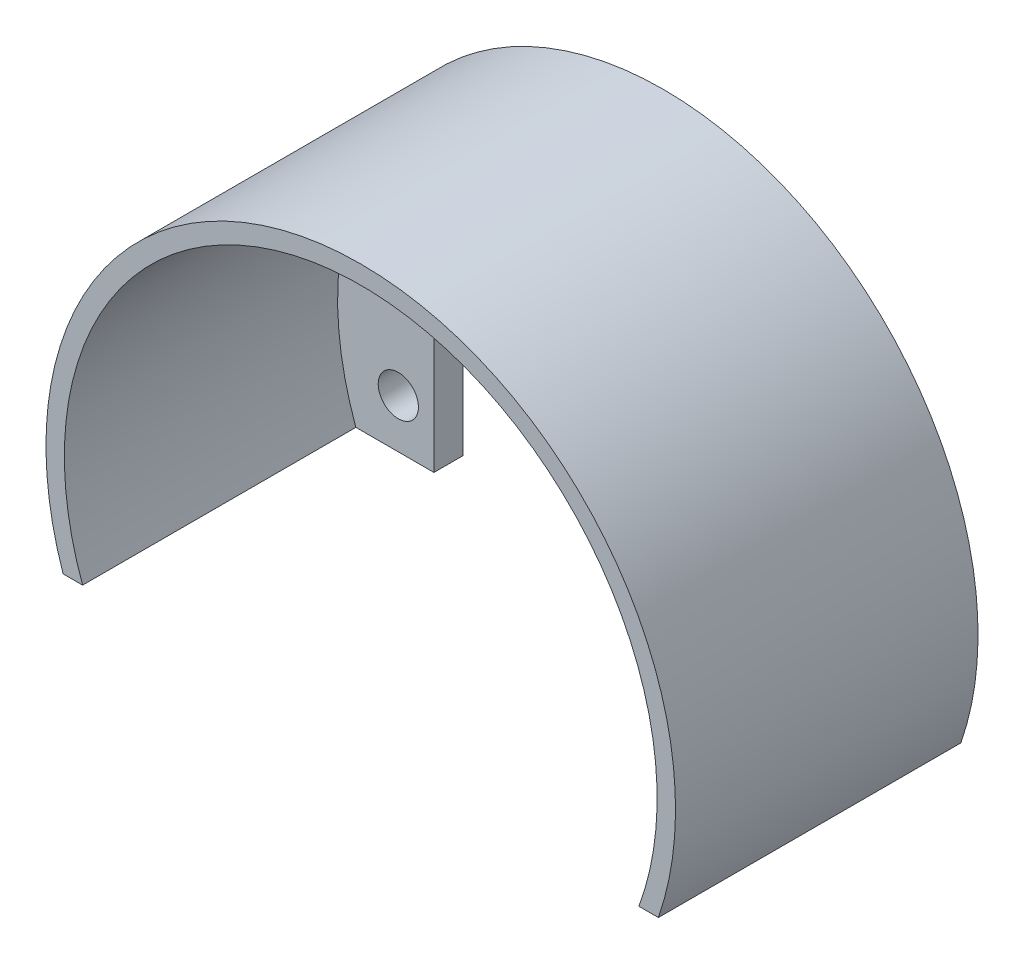
from build123d import *

# Parameters (mm, degrees)
CROQUIS1_R              = 2.060946668
SALIENTE_EXTRUIR1_DEPTH = 3
SALIENTE_EXTRUIR2_DEPTH = 28


with BuildPart() as part:
    # Croquis1 → Saliente-Extruir1 (new body)
    with BuildSketch(Plane.XY):
        with BuildLine():
            Line((-17.644764035, 22.151573595), (23.355235965, 22.151573595))
            Line((23.355235965, 22.151573595), (23.355235965, 1.151573595))
            Line((23.355235965, 1.151573595), (33.355235965, 1.151573595))
            ThreePointArc((33.355235965, 1.151573595), (2.855235965, 43.908355827), (-27.644764035, 1.151573595))
            Line((-27.644764035, 1.151573595), (-17.644764035, 1.151573595))
            Line((-17.644764035, 1.151573595), (-17.644764035, 22.151573595))
        make_face()
        with Locations((27.005235965, 6.151573595)):
            Circle(CROQUIS1_R, mode=Mode.SUBTRACT)
        with Locations((-21.294764035, 6.151573595)):
            Circle(CROQUIS1_R, mode=Mode.SUBTRACT)
        with Locations((-21.294764035, 16.151573595)):
            Circle(CROQUIS1_R, mode=Mode.SUBTRACT)
        with Locations((27.005235965, 16.151573595)):
            Circle(CROQUIS1_R, mode=Mode.SUBTRACT)
    extrude(amount=SALIENTE_EXTRUIR1_DEPTH)

    # Croquis2 → Saliente-Extruir2 (add)
    with BuildSketch(Plane.XY.offset(3)):
        with BuildLine():
            Line((-27.644764035, 1.151573595), (-25.644764035, 1.151573595))
            ThreePointArc((-25.644764035, 1.151573595), (2.855235965, 42.024258692), (31.355235965, 1.151573595))
            Line((31.355235965, 1.151573595), (33.355235965, 1.151573595))
            ThreePointArc((33.355235965, 1.151573595), (2.855235965, 43.908355827), (-27.644764035, 1.151573595))
        make_face()
    extrude(amount=SALIENTE_EXTRUIR2_DEPTH)


solid = part.part
